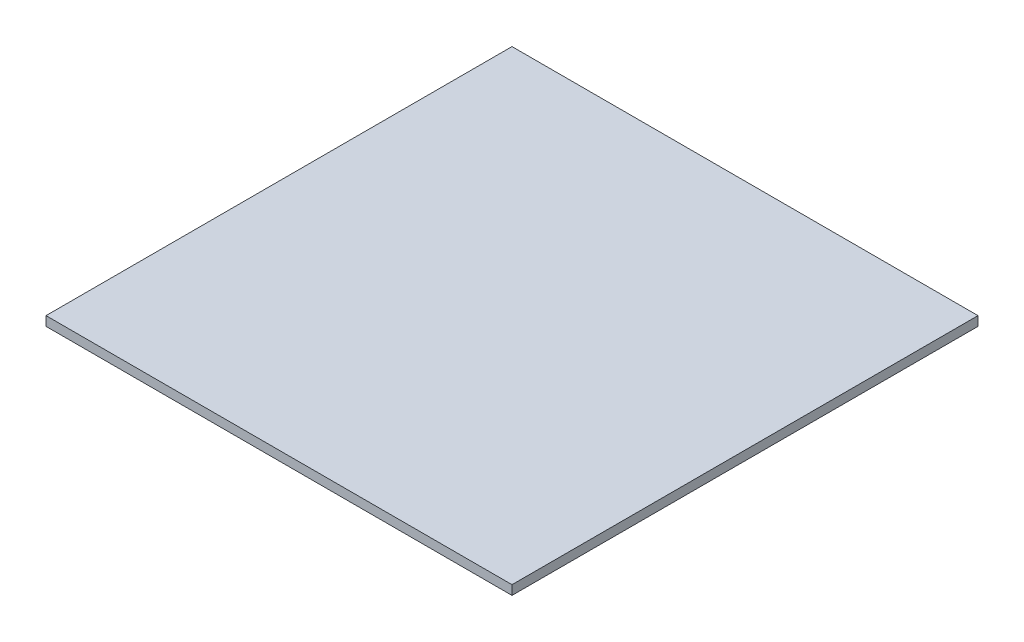
from build123d import *

# Parameters (mm, degrees)
SKETCH1_W           = 200
SKETCH1_H           = 200
BOSS_EXTRUDE1_DEPTH = 4


with BuildPart() as part:
    # Sketch1 → Boss-Extrude1 (new body)
    with BuildSketch(Plane(origin=(0, 0, 0), x_dir=(1, 0, 0), z_dir=(0, 1, 0))):
        with Locations((100, 100)):
            Rectangle(SKETCH1_W, SKETCH1_H)
    extrude(amount=BOSS_EXTRUDE1_DEPTH)


solid = part.part
